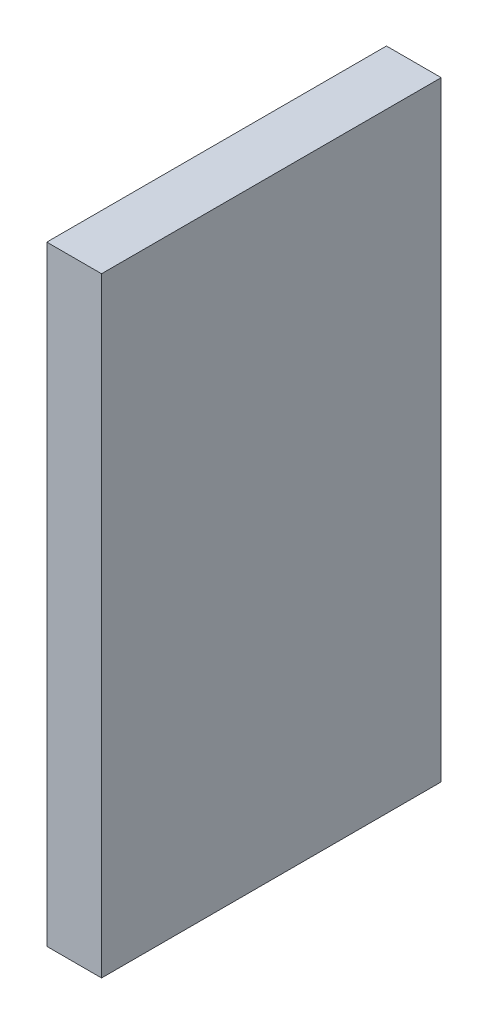
from build123d import *

# Parameters (mm, degrees)
CROQUIS1_W              = 18.6
CROQUIS1_H              = 33.4
SALIENTE_EXTRUIR1_DEPTH = 3


with BuildPart() as part:
    # Croquis1 → Saliente-Extruir1 (new body)
    with BuildSketch(Plane(origin=(0, 0, 0), x_dir=(0, 0, -1), z_dir=(1, 0, 0))):
        with Locations((-16.572420234, -7.954761712)):
            Rectangle(CROQUIS1_W, CROQUIS1_H)
    extrude(amount=SALIENTE_EXTRUIR1_DEPTH)


solid = part.part
